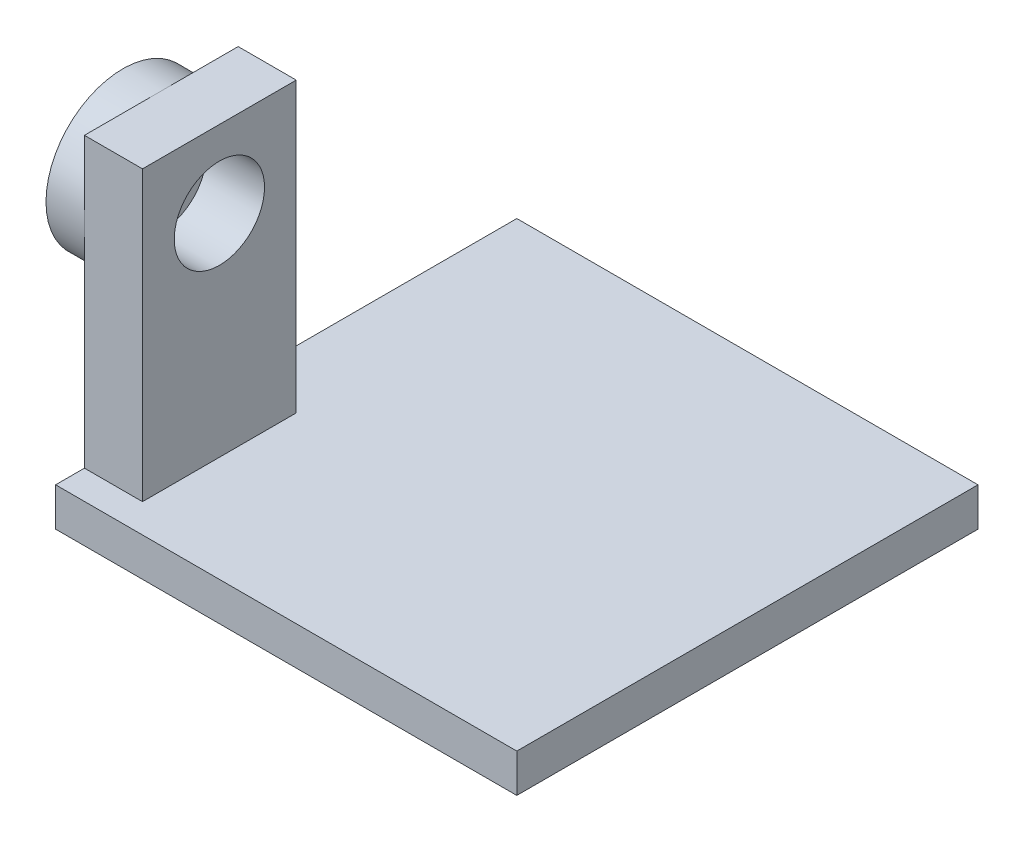
from build123d import *

# Parameters (mm, degrees)
SKETCH3_W           = 24
SKETCH3_H           = 24
BOSS_EXTRUDE1_DEPTH = 2
SKETCH4_W           = 3.021973807
SKETCH4_H           = 8
BOSS_EXTRUDE2_DEPTH = 15
SKETCH6_R           = 2.35
CUT_EXTRUDE1_DEPTH  = 3.2
SKETCH7_R           = 4
BOSS_EXTRUDE3_DEPTH = 2
SKETCH8_R           = 1
CUT_EXTRUDE2_DEPTH  = 2
SKETCH9_R           = 1.25
CUT_EXTRUDE3_DEPTH  = 0.3


with BuildPart() as part:
    # Sketch3 → Boss-Extrude1 (new body)
    with BuildSketch(Plane(origin=(0, 0, 0), x_dir=(1, 0, 0), z_dir=(0, 1, 0))):
        with Locations((-15.971223022, 1.424460432)):
            Rectangle(SKETCH3_W, SKETCH3_H)
    extrude(amount=BOSS_EXTRUDE1_DEPTH)

    # Sketch4 → Boss-Extrude2 (add)
    with BuildSketch(Plane(origin=(0, 2, 0), x_dir=(1, 0, 0), z_dir=(0, 1, 0))):
        with Locations((-26.460236118, -5.075539568)):
            Rectangle(SKETCH4_W, SKETCH4_H)
    extrude(amount=BOSS_EXTRUDE2_DEPTH)

    # Sketch6 → Cut-Extrude1 (cut)
    with BuildSketch(Plane(origin=(-24.949249215, 0, 0), x_dir=(0, 0, -1), z_dir=(1, 0, 0))):
        with Locations((-5.075539568, 13)):
            Circle(SKETCH6_R)
    extrude(amount=-CUT_EXTRUDE1_DEPTH, mode=Mode.SUBTRACT)

    # Sketch7 → Boss-Extrude3 (add)
    with BuildSketch(Plane.ZY.offset(27.971223022)):
        with Locations((5.075539568, 13)):
            Circle(SKETCH7_R)
    extrude(amount=BOSS_EXTRUDE3_DEPTH)

    # Sketch8 → Cut-Extrude2 (cut)
    with BuildSketch(Plane.ZY.offset(29.971223022)):
        with Locations((5.075539568, 13)):
            Circle(SKETCH8_R)
    extrude(amount=-CUT_EXTRUDE2_DEPTH, mode=Mode.SUBTRACT)

    # Sketch9 → Cut-Extrude3 (cut)
    with BuildSketch(Plane.ZY.offset(29.971223022)):
        with Locations((5.075539568, 13)):
            Circle(SKETCH9_R)
    extrude(amount=-CUT_EXTRUDE3_DEPTH, mode=Mode.SUBTRACT)


solid = part.part
